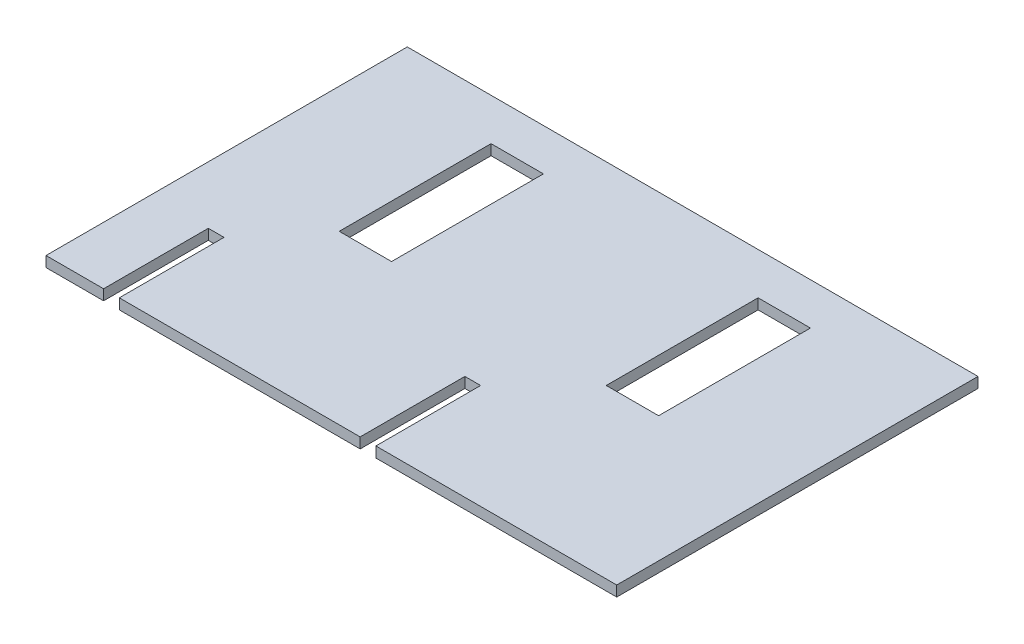
from build123d import *

# Parameters (mm, degrees)
SKETCH1_W           = 54.5
SKETCH1_H           = 34.5
BOSS_EXTRUDE1_DEPTH = 1
SKETCH6_W           = 5
SKETCH6_H           = 14.5
CUT_EXTRUDE1_DEPTH  = 2
SKETCH9_W           = 5
SKETCH9_H           = 14.5
CUT_EXTRUDE2_DEPTH  = 2
SKETCH27_W          = 1.5
SKETCH27_H          = 10
CUT_EXTRUDE3_DEPTH  = 2
SKETCH37_W          = 1.5
SKETCH37_H          = 10
CUT_EXTRUDE10_DEPTH = 2


with BuildPart() as part:
    # Sketch1 → Boss-Extrude1 (new body)
    with BuildSketch(Plane(origin=(0, 0, 0), x_dir=(1, 0, 0), z_dir=(0, 1, 0))):
        Rectangle(SKETCH1_W, SKETCH1_H)
    extrude(amount=BOSS_EXTRUDE1_DEPTH)

    # Sketch6 → Cut-Extrude1 (cut)
    with BuildSketch(Plane(origin=(0, 1, 0), x_dir=(1, 0, 0), z_dir=(0, 1, 0))):
        with Locations((-12.75, 6)):
            Rectangle(SKETCH6_W, SKETCH6_H)
    extrude(amount=-CUT_EXTRUDE1_DEPTH, mode=Mode.SUBTRACT)

    # Sketch9 → Cut-Extrude2 (cut)
    with BuildSketch(Plane(origin=(0, 1, 0), x_dir=(1, 0, 0), z_dir=(0, 1, 0))):
        with Locations((12.75, 6)):
            Rectangle(SKETCH9_W, SKETCH9_H)
    extrude(amount=-CUT_EXTRUDE2_DEPTH, mode=Mode.SUBTRACT)

    # Sketch27 → Cut-Extrude3 (cut)
    with BuildSketch(Plane(origin=(0, 1, 0), x_dir=(1, 0, 0), z_dir=(0, 1, 0))):
        with Locations((-21, -12.25)):
            Rectangle(SKETCH27_W, SKETCH27_H)
    extrude(amount=-CUT_EXTRUDE3_DEPTH, mode=Mode.SUBTRACT)

    # Sketch37 → Cut-Extrude10 (cut)
    with BuildSketch(Plane(origin=(0, 1, 0), x_dir=(1, 0, 0), z_dir=(0, 1, 0))):
        with Locations((3.5, -12.25)):
            Rectangle(SKETCH37_W, SKETCH37_H)
    extrude(amount=-CUT_EXTRUDE10_DEPTH, mode=Mode.SUBTRACT)


solid = part.part
